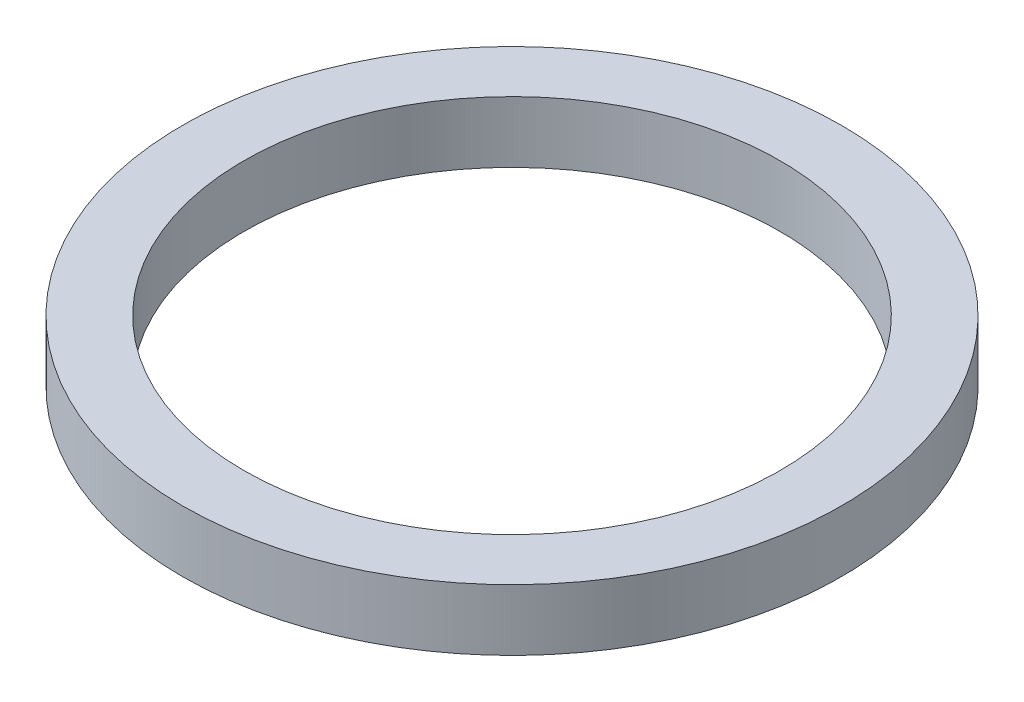
from build123d import *

# Parameters (mm, degrees)
SKETCH_1_R      = 43
SKETCH_1_R_2    = 35
EXTRUDE_1_DEPTH = 8


with BuildPart() as part:
    # 草图1 → 凸台-拉伸1 (new body)
    with BuildSketch(Plane(origin=(0, 0, 0), x_dir=(1, 0, 0), z_dir=(0, 1, 0))):
        Circle(SKETCH_1_R)
        Circle(SKETCH_1_R_2, mode=Mode.SUBTRACT)
    extrude(amount=EXTRUDE_1_DEPTH)


solid = part.part
